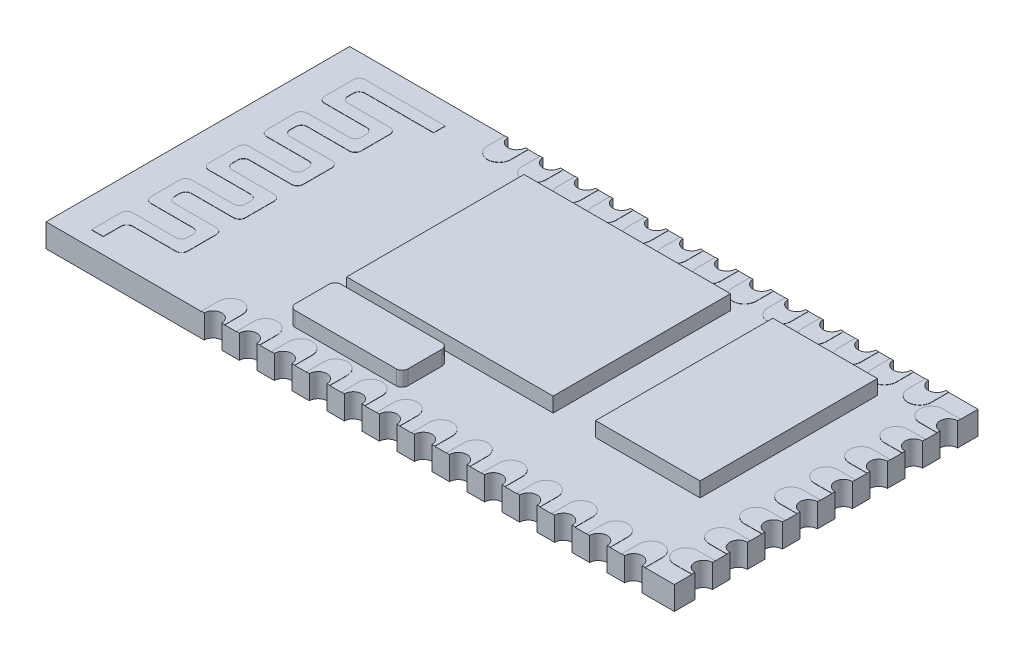
from build123d import *

# Parameters (mm, degrees)
SKETCH1_W           = 26.9
SKETCH1_H           = 13
BOSS_EXTRUDE1_DEPTH = 1
SKETCH2_W           = 4.474027776
SKETCH2_H           = 7.592289559
SKETCH2_W_2         = 8.839594273
BOSS_EXTRUDE2_DEPTH = 0.63
BOSS_EXTRUDE3_DEPTH = 0.01
BOSS_EXTRUDE4_DEPTH = 0.63
BOSS_EXTRUDE5_DEPTH = 0.01
SKETCH7_W           = 22.420690482
SKETCH7_H           = 1.871477004
CUT_EXTRUDE1_DEPTH  = 2.01
SKETCH8_R           = 0.375
CUT_EXTRUDE2_DEPTH  = 2.01
LPATTERN1_COUNT     = 13
LPATTERN1_PITCH     = 1.5
SKETCH9_R           = 0.375
CUT_EXTRUDE3_DEPTH  = 2.01
LPATTERN2_COUNT     = 8
LPATTERN2_PITCH     = 1.5


with BuildPart() as part:
    # Sketch1 → Boss-Extrude1 (new body)
    with BuildSketch(Plane(origin=(0, 0, 0), x_dir=(1, 0, 0), z_dir=(0, 1, 0))):
        with Locations((13.45, 6.5)):
            Rectangle(SKETCH1_W, SKETCH1_H)
    extrude(amount=BOSS_EXTRUDE1_DEPTH)

    # Sketch2 → Boss-Extrude2 (add)
    with BuildSketch(Plane(origin=(0, 1, 0), x_dir=(1, 0, 0), z_dir=(0, 1, 0))):
        with Locations((22.000611186, 7.559584322)):
            Rectangle(SKETCH2_W, SKETCH2_H)
        with Locations((13.527073731, 7.559584322)):
            Rectangle(SKETCH2_W_2, SKETCH2_H)
    extrude(amount=BOSS_EXTRUDE2_DEPTH)

    # Sketch3 → Boss-Extrude3 (add)
    with BuildSketch(Plane(origin=(0, 1, 0), x_dir=(1, 0, 0), z_dir=(0, 1, 0))):
        with BuildLine():
            Line((5.001748059, 12.091352807), (1.569925159, 12.091352807))
            ThreePointArc((1.569925159, 12.091352807), (1.393148464, 12.018129502), (1.319925159, 11.841352807))
            Line((1.319925159, 11.841352807), (1.319925159, 10.602651625))
            ThreePointArc((1.319925159, 10.602651625), (1.393148464, 10.42587493), (1.569925159, 10.352651625))
            Line((1.569925159, 10.352651625), (3.374727347, 10.352651625))
            ThreePointArc((3.374727347, 10.352651625), (3.551504042, 10.27942832), (3.624727347, 10.102651625))
            Line((3.624727347, 10.102651625), (3.624727347, 9.863950443))
            ThreePointArc((3.624727347, 9.863950443), (3.551504042, 9.687173748), (3.374727347, 9.613950443))
            Line((3.374727347, 9.613950443), (1.569925159, 9.613950443))
            ThreePointArc((1.569925159, 9.613950443), (1.393148464, 9.540727138), (1.319925159, 9.363950443))
            Line((1.319925159, 9.363950443), (1.319925159, 8.125249261))
            ThreePointArc((1.319925159, 8.125249261), (1.393148464, 7.948472566), (1.569925159, 7.875249261))
            Line((1.569925159, 7.875249261), (3.374727347, 7.875249261))
            ThreePointArc((3.374727347, 7.875249261), (3.551504042, 7.802025956), (3.624727347, 7.625249261))
            Line((3.624727347, 7.625249261), (3.624727347, 7.386548079))
            ThreePointArc((3.624727347, 7.386548079), (3.551504042, 7.209771384), (3.374727347, 7.136548079))
            Line((3.374727347, 7.136548079), (1.569925159, 7.136548079))
            ThreePointArc((1.569925159, 7.136548079), (1.393148464, 7.063324774), (1.319925159, 6.886548079))
            Line((1.319925159, 6.886548079), (1.319925159, 5.647846897))
            ThreePointArc((1.319925159, 5.647846897), (1.393148464, 5.471070202), (1.569925159, 5.397846897))
            Line((1.569925159, 5.397846897), (3.374727347, 5.397846897))
            ThreePointArc((3.374727347, 5.397846897), (3.551504042, 5.324623592), (3.624727347, 5.147846897))
            Line((3.624727347, 5.147846897), (3.624727347, 4.909145715))
            ThreePointArc((3.624727347, 4.909145715), (3.551504042, 4.732369019), (3.374727347, 4.659145715))
            Line((3.374727347, 4.659145715), (1.569925159, 4.659145715))
            ThreePointArc((1.569925159, 4.659145715), (1.393148464, 4.58592241), (1.319925159, 4.409145715))
            Line((1.319925159, 4.409145715), (1.319925159, 3.170444533))
            ThreePointArc((1.319925159, 3.170444533), (1.393148464, 2.993667837), (1.569925159, 2.920444533))
            Line((1.569925159, 2.920444533), (3.374727347, 2.920444533))
            ThreePointArc((3.374727347, 2.920444533), (3.551504042, 2.847221228), (3.624727347, 2.670444533))
            Line((3.624727347, 2.670444533), (3.624727347, 2.431743351))
            ThreePointArc((3.624727347, 2.431743351), (3.551504042, 2.254966655), (3.374727347, 2.181743351))
            Line((3.374727347, 2.181743351), (1.527027373, 2.181743351))
            ThreePointArc((1.527027373, 2.181743351), (1.350250678, 2.108520046), (1.277027373, 1.931743351))
            Line((1.277027373, 1.931743351), (1.277027373, 0.673866206))
            Line((1.277027373, 0.673866206), (1.777027373, 0.673866206))
            Line((1.777027373, 0.673866206), (1.777027373, 1.431743351))
            ThreePointArc((1.777027373, 1.431743351), (1.850250678, 1.608520046), (2.027027373, 1.681743351))
            Line((2.027027373, 1.681743351), (3.874727347, 1.681743351))
            ThreePointArc((3.874727347, 1.681743351), (4.051504042, 1.754966655), (4.124727347, 1.931743351))
            Line((4.124727347, 1.931743351), (4.124727347, 3.170444533))
            ThreePointArc((4.124727347, 3.170444533), (4.051504042, 3.347221228), (3.874727347, 3.420444533))
            Line((3.874727347, 3.420444533), (2.069925159, 3.420444533))
            ThreePointArc((2.069925159, 3.420444533), (1.893148464, 3.493667837), (1.819925159, 3.670444533))
            Line((1.819925159, 3.670444533), (1.819925159, 3.909145715))
            ThreePointArc((1.819925159, 3.909145715), (1.893148464, 4.08592241), (2.069925159, 4.159145715))
            Line((2.069925159, 4.159145715), (3.874727347, 4.159145715))
            ThreePointArc((3.874727347, 4.159145715), (4.051504042, 4.232369019), (4.124727347, 4.409145715))
            Line((4.124727347, 4.409145715), (4.124727347, 5.647846897))
            ThreePointArc((4.124727347, 5.647846897), (4.051504042, 5.824623592), (3.874727347, 5.897846897))
            Line((3.874727347, 5.897846897), (2.069925159, 5.897846897))
            ThreePointArc((2.069925159, 5.897846897), (1.893148464, 5.971070202), (1.819925159, 6.147846897))
            Line((1.819925159, 6.147846897), (1.819925159, 6.386548079))
            ThreePointArc((1.819925159, 6.386548079), (1.893148464, 6.563324774), (2.069925159, 6.636548079))
            Line((2.069925159, 6.636548079), (3.874727347, 6.636548079))
            ThreePointArc((3.874727347, 6.636548079), (4.051504042, 6.709771384), (4.124727347, 6.886548079))
            Line((4.124727347, 6.886548079), (4.124727347, 8.125249261))
            ThreePointArc((4.124727347, 8.125249261), (4.051504042, 8.302025956), (3.874727347, 8.375249261))
            Line((3.874727347, 8.375249261), (2.069925159, 8.375249261))
            ThreePointArc((2.069925159, 8.375249261), (1.893148464, 8.448472566), (1.819925159, 8.625249261))
            Line((1.819925159, 8.625249261), (1.819925159, 8.863950443))
            ThreePointArc((1.819925159, 8.863950443), (1.893148464, 9.040727138), (2.069925159, 9.113950443))
            Line((2.069925159, 9.113950443), (3.874727347, 9.113950443))
            ThreePointArc((3.874727347, 9.113950443), (4.051504042, 9.187173748), (4.124727347, 9.363950443))
            Line((4.124727347, 9.363950443), (4.124727347, 10.602651625))
            ThreePointArc((4.124727347, 10.602651625), (4.051504042, 10.77942832), (3.874727347, 10.852651625))
            Line((3.874727347, 10.852651625), (2.069925159, 10.852651625))
            ThreePointArc((2.069925159, 10.852651625), (1.893148464, 10.92587493), (1.819925159, 11.102651625))
            Line((1.819925159, 11.102651625), (1.819925159, 11.341352807))
            ThreePointArc((1.819925159, 11.341352807), (1.893148464, 11.518129502), (2.069925159, 11.591352807))
            Line((2.069925159, 11.591352807), (5.001748059, 11.591352807))
            Line((5.001748059, 11.591352807), (5.001748059, 12.091352807))
        make_face()
    extrude(amount=BOSS_EXTRUDE3_DEPTH)

    # Sketch4 → Boss-Extrude4 (add)
    with BuildSketch(Plane(origin=(0, 1, 0), x_dir=(1, 0, 0), z_dir=(0, 1, 0))):
        with BuildLine():
            Line((9.253087544, 3.367848777), (13.579614478, 3.367848777))
            ThreePointArc((13.579614478, 3.367848777), (13.756391173, 3.294625473), (13.829614478, 3.117848777))
            Line((13.829614478, 3.117848777), (13.829614478, 1.665545748))
            ThreePointArc((13.829614478, 1.665545748), (13.756391173, 1.488769052), (13.579614478, 1.415545748))
            Line((13.579614478, 1.415545748), (9.253087544, 1.415545748))
            ThreePointArc((9.253087544, 1.415545748), (9.076310848, 1.488769052), (9.003087544, 1.665545748))
            Line((9.003087544, 1.665545748), (9.003087544, 3.117848777))
            ThreePointArc((9.003087544, 3.117848777), (9.076310848, 3.294625473), (9.253087544, 3.367848777))
        make_face()
    extrude(amount=BOSS_EXTRUDE4_DEPTH)

    # Sketch5 → Boss-Extrude5 (add)
    with BuildSketch(Plane(origin=(0, 1, 0), x_dir=(1, 0, 0), z_dir=(0, 1, 0))):
        with BuildLine():
            Line((26.15, 12.25), (28.15, 12.25))
            ThreePointArc((28.15, 12.25), (28.65, 11.75), (28.15, 11.25))
            Line((28.15, 11.25), (26.15, 11.25))
            ThreePointArc((26.15, 11.25), (25.65, 11.75), (26.15, 12.25))
        make_face()
        with BuildLine():
            Line((26.15, 10.75), (28.15, 10.75))
            ThreePointArc((28.15, 10.75), (28.65, 10.25), (28.15, 9.75))
            Line((28.15, 9.75), (26.15, 9.75))
            ThreePointArc((26.15, 9.75), (25.65, 10.25), (26.15, 10.75))
        make_face()
        with BuildLine():
            Line((26.15, 9.25), (28.15, 9.25))
            ThreePointArc((28.15, 9.25), (28.65, 8.75), (28.15, 8.25))
            Line((28.15, 8.25), (26.15, 8.25))
            ThreePointArc((26.15, 8.25), (25.65, 8.75), (26.15, 9.25))
        make_face()
        with BuildLine():
            Line((26.15, 7.75), (28.15, 7.75))
            ThreePointArc((28.15, 7.75), (28.65, 7.25), (28.15, 6.75))
            Line((28.15, 6.75), (26.15, 6.75))
            ThreePointArc((26.15, 6.75), (25.65, 7.25), (26.15, 7.75))
        make_face()
        with BuildLine():
            Line((26.15, 6.25), (28.15, 6.25))
            ThreePointArc((28.15, 6.25), (28.65, 5.75), (28.15, 5.25))
            Line((28.15, 5.25), (26.15, 5.25))
            ThreePointArc((26.15, 5.25), (25.65, 5.75), (26.15, 6.25))
        make_face()
        with BuildLine():
            Line((26.15, 4.75), (28.15, 4.75))
            ThreePointArc((28.15, 4.75), (28.65, 4.25), (28.15, 3.75))
            Line((28.15, 3.75), (26.15, 3.75))
            ThreePointArc((26.15, 3.75), (25.65, 4.25), (26.15, 4.75))
        make_face()
        with BuildLine():
            Line((26.15, 3.25), (28.15, 3.25))
            ThreePointArc((28.15, 3.25), (28.65, 2.75), (28.15, 2.25))
            Line((28.15, 2.25), (26.15, 2.25))
            ThreePointArc((26.15, 2.25), (25.65, 2.75), (26.15, 3.25))
        make_face()
        with BuildLine():
            Line((26.15, 1.75), (28.15, 1.75))
            ThreePointArc((28.15, 1.75), (28.65, 1.25), (28.15, 0.75))
            Line((28.15, 0.75), (26.15, 0.75))
            ThreePointArc((26.15, 0.75), (25.65, 1.25), (26.15, 1.75))
        make_face()
        with BuildLine():
            Line((24.65, 12.25), (24.65, 14.25))
            ThreePointArc((24.65, 14.25), (25.15, 14.75), (25.65, 14.25))
            Line((25.65, 14.25), (25.65, 12.25))
            ThreePointArc((25.65, 12.25), (25.15, 11.75), (24.65, 12.25))
        make_face()
        with BuildLine():
            Line((23.15, 12.25), (23.15, 14.25))
            ThreePointArc((23.15, 14.25), (23.65, 14.75), (24.15, 14.25))
            Line((24.15, 14.25), (24.15, 12.25))
            ThreePointArc((24.15, 12.25), (23.65, 11.75), (23.15, 12.25))
        make_face()
        with BuildLine():
            Line((21.65, 12.25), (21.65, 14.25))
            ThreePointArc((21.65, 14.25), (22.15, 14.75), (22.65, 14.25))
            Line((22.65, 14.25), (22.65, 12.25))
            ThreePointArc((22.65, 12.25), (22.15, 11.75), (21.65, 12.25))
        make_face()
        with BuildLine():
            Line((20.15, 12.25), (20.15, 14.25))
            ThreePointArc((20.15, 14.25), (20.65, 14.75), (21.15, 14.25))
            Line((21.15, 14.25), (21.15, 12.25))
            ThreePointArc((21.15, 12.25), (20.65, 11.75), (20.15, 12.25))
        make_face()
        with BuildLine():
            Line((18.65, 12.25), (18.65, 14.25))
            ThreePointArc((18.65, 14.25), (19.15, 14.75), (19.65, 14.25))
            Line((19.65, 14.25), (19.65, 12.25))
            ThreePointArc((19.65, 12.25), (19.15, 11.75), (18.65, 12.25))
        make_face()
        with BuildLine():
            Line((17.15, 12.25), (17.15, 14.25))
            ThreePointArc((17.15, 14.25), (17.65, 14.75), (18.15, 14.25))
            Line((18.15, 14.25), (18.15, 12.25))
            ThreePointArc((18.15, 12.25), (17.65, 11.75), (17.15, 12.25))
        make_face()
        with BuildLine():
            Line((15.65, 12.25), (15.65, 14.25))
            ThreePointArc((15.65, 14.25), (16.15, 14.75), (16.65, 14.25))
            Line((16.65, 14.25), (16.65, 12.25))
            ThreePointArc((16.65, 12.25), (16.15, 11.75), (15.65, 12.25))
        make_face()
        with BuildLine():
            Line((14.15, 12.25), (14.15, 14.25))
            ThreePointArc((14.15, 14.25), (14.65, 14.75), (15.15, 14.25))
            Line((15.15, 14.25), (15.15, 12.25))
            ThreePointArc((15.15, 12.25), (14.65, 11.75), (14.15, 12.25))
        make_face()
        with BuildLine():
            Line((12.65, 12.25), (12.65, 14.25))
            ThreePointArc((12.65, 14.25), (13.15, 14.75), (13.65, 14.25))
            Line((13.65, 14.25), (13.65, 12.25))
            ThreePointArc((13.65, 12.25), (13.15, 11.75), (12.65, 12.25))
        make_face()
        with BuildLine():
            Line((11.15, 12.25), (11.15, 14.25))
            ThreePointArc((11.15, 14.25), (11.65, 14.75), (12.15, 14.25))
            Line((12.15, 14.25), (12.15, 12.25))
            ThreePointArc((12.15, 12.25), (11.65, 11.75), (11.15, 12.25))
        make_face()
        with BuildLine():
            Line((9.65, 12.25), (9.65, 14.25))
            ThreePointArc((9.65, 14.25), (10.15, 14.75), (10.65, 14.25))
            Line((10.65, 14.25), (10.65, 12.25))
            ThreePointArc((10.65, 12.25), (10.15, 11.75), (9.65, 12.25))
        make_face()
        with BuildLine():
            Line((8.15, 12.25), (8.15, 14.25))
            ThreePointArc((8.15, 14.25), (8.65, 14.75), (9.15, 14.25))
            Line((9.15, 14.25), (9.15, 12.25))
            ThreePointArc((9.15, 12.25), (8.65, 11.75), (8.15, 12.25))
        make_face()
        with BuildLine():
            Line((6.65, 12.25), (6.65, 14.25))
            ThreePointArc((6.65, 14.25), (7.15, 14.75), (7.65, 14.25))
            Line((7.65, 14.25), (7.65, 12.25))
            ThreePointArc((7.65, 12.25), (7.15, 11.75), (6.65, 12.25))
        make_face()
        with BuildLine():
            Line((24.65, 0.75), (24.65, -1.25))
            ThreePointArc((24.65, -1.25), (25.15, -1.75), (25.65, -1.25))
            Line((25.65, -1.25), (25.65, 0.75))
            ThreePointArc((25.65, 0.75), (25.15, 1.25), (24.65, 0.75))
        make_face()
        with BuildLine():
            Line((23.15, 0.75), (23.15, -1.25))
            ThreePointArc((23.15, -1.25), (23.65, -1.75), (24.15, -1.25))
            Line((24.15, -1.25), (24.15, 0.75))
            ThreePointArc((24.15, 0.75), (23.65, 1.25), (23.15, 0.75))
        make_face()
        with BuildLine():
            Line((21.65, 0.75), (21.65, -1.25))
            ThreePointArc((21.65, -1.25), (22.15, -1.75), (22.65, -1.25))
            Line((22.65, -1.25), (22.65, 0.75))
            ThreePointArc((22.65, 0.75), (22.15, 1.25), (21.65, 0.75))
        make_face()
        with BuildLine():
            Line((20.15, 0.75), (20.15, -1.25))
            ThreePointArc((20.15, -1.25), (20.65, -1.75), (21.15, -1.25))
            Line((21.15, -1.25), (21.15, 0.75))
            ThreePointArc((21.15, 0.75), (20.65, 1.25), (20.15, 0.75))
        make_face()
        with BuildLine():
            Line((18.65, 0.75), (18.65, -1.25))
            ThreePointArc((18.65, -1.25), (19.15, -1.75), (19.65, -1.25))
            Line((19.65, -1.25), (19.65, 0.75))
            ThreePointArc((19.65, 0.75), (19.15, 1.25), (18.65, 0.75))
        make_face()
        with BuildLine():
            Line((17.15, 0.75), (17.15, -1.25))
            ThreePointArc((17.15, -1.25), (17.65, -1.75), (18.15, -1.25))
            Line((18.15, -1.25), (18.15, 0.75))
            ThreePointArc((18.15, 0.75), (17.65, 1.25), (17.15, 0.75))
        make_face()
        with BuildLine():
            Line((15.65, 0.75), (15.65, -1.25))
            ThreePointArc((15.65, -1.25), (16.15, -1.75), (16.65, -1.25))
            Line((16.65, -1.25), (16.65, 0.75))
            ThreePointArc((16.65, 0.75), (16.15, 1.25), (15.65, 0.75))
        make_face()
        with BuildLine():
            Line((14.15, 0.75), (14.15, -1.25))
            ThreePointArc((14.15, -1.25), (14.65, -1.75), (15.15, -1.25))
            Line((15.15, -1.25), (15.15, 0.75))
            ThreePointArc((15.15, 0.75), (14.65, 1.25), (14.15, 0.75))
        make_face()
        with BuildLine():
            Line((12.65, 0.75), (12.65, -1.25))
            ThreePointArc((12.65, -1.25), (13.15, -1.75), (13.65, -1.25))
            Line((13.65, -1.25), (13.65, 0.75))
            ThreePointArc((13.65, 0.75), (13.15, 1.25), (12.65, 0.75))
        make_face()
        with BuildLine():
            Line((11.15, 0.75), (11.15, -1.25))
            ThreePointArc((11.15, -1.25), (11.65, -1.75), (12.15, -1.25))
            Line((12.15, -1.25), (12.15, 0.75))
            ThreePointArc((12.15, 0.75), (11.65, 1.25), (11.15, 0.75))
        make_face()
        with BuildLine():
            Line((9.65, 0.75), (9.65, -1.25))
            ThreePointArc((9.65, -1.25), (10.15, -1.75), (10.65, -1.25))
            Line((10.65, -1.25), (10.65, 0.75))
            ThreePointArc((10.65, 0.75), (10.15, 1.25), (9.65, 0.75))
        make_face()
        with BuildLine():
            Line((8.15, 0.75), (8.15, -1.25))
            ThreePointArc((8.15, -1.25), (8.65, -1.75), (9.15, -1.25))
            Line((9.15, -1.25), (9.15, 0.75))
            ThreePointArc((9.15, 0.75), (8.65, 1.25), (8.15, 0.75))
        make_face()
        with BuildLine():
            Line((6.65, 0.75), (6.65, -1.25))
            ThreePointArc((6.65, -1.25), (7.15, -1.75), (7.65, -1.25))
            Line((7.65, -1.25), (7.65, 0.75))
            ThreePointArc((7.65, 0.75), (7.15, 1.25), (6.65, 0.75))
        make_face()
    extrude(amount=BOSS_EXTRUDE5_DEPTH)

    # Sketch7 → Cut-Extrude1 (cut, through all)
    with BuildSketch(Plane(origin=(0, 1.01, 0), x_dir=(1, 0, 0), z_dir=(0, 1, 0))):
        with BuildLine():
            Line((7.65, 14.25), (7.65, 13))
            Line((7.65, 13), (26.9, 13))
            Line((26.9, 13), (26.9, 15.004533592))
            Line((26.9, 15.004533592), (6.65, 15.004533592))
            Line((6.65, 15.004533592), (6.65, 14.25))
            ThreePointArc((6.65, 14.25), (7.15, 14.75), (7.65, 14.25))
        make_face()
        Polygon((26.9, 15.004533592), (26.9, 13), (26.9, 0), (29.070690482, 0), (29.070690482, 15.004533592), align=None)
        with BuildLine():
            Line((6.65, 14.25), (6.65, 13))
            Line((6.65, 13), (7.65, 13))
            Line((7.65, 13), (7.65, 14.25))
            ThreePointArc((7.65, 14.25), (7.15, 14.75), (6.65, 14.25))
        make_face()
        with Locations((17.860345241, -0.935738502)):
            Rectangle(SKETCH7_W, SKETCH7_H)
    extrude(amount=-CUT_EXTRUDE1_DEPTH, mode=Mode.SUBTRACT)

    # Sketch8 → Cut-Extrude2 (cut, through all)
    with BuildSketch(Plane(origin=(0, 1.01, 0), x_dir=(1, 0, 0), z_dir=(0, 1, 0))):
        with Locations((7.15, 13)):
            Circle(SKETCH8_R)
        with Locations((7.15, 0)):
            Circle(SKETCH8_R)
    cut_extrude2 = extrude(amount=-CUT_EXTRUDE2_DEPTH, mode=Mode.SUBTRACT)

    # LPattern1: Cut-Extrude2 ×13
    with Locations(*[(i * LPATTERN1_PITCH, 0, 0) for i in range(1, LPATTERN1_COUNT)]):
        add(cut_extrude2, mode=Mode.SUBTRACT)

    # Sketch9 → Cut-Extrude3 (cut, through all)
    with BuildSketch(Plane(origin=(0, 1.01, 0), x_dir=(1, 0, 0), z_dir=(0, 1, 0))):
        with Locations((26.9, 11.75)):
            Circle(SKETCH9_R)
    cut_extrude3 = extrude(amount=-CUT_EXTRUDE3_DEPTH, mode=Mode.SUBTRACT)

    # LPattern2: Cut-Extrude3 ×8
    with Locations(*[(0, 0, i * LPATTERN2_PITCH) for i in range(1, LPATTERN2_COUNT)]):
        add(cut_extrude3, mode=Mode.SUBTRACT)


solid = part.part
